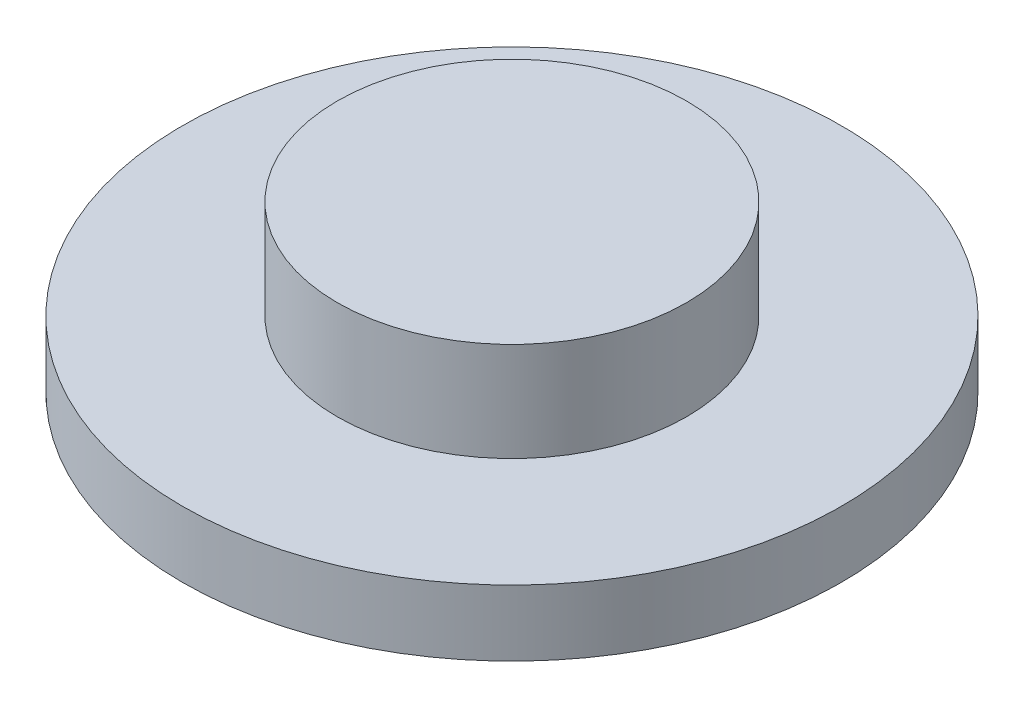
from build123d import *

# Parameters (mm, degrees)
SKETCH_1_R      = 15
EXTRUDE_1_DEPTH = 3
SKETCH_2_R      = 7.95
EXTRUDE_2_DEPTH = 4.5


with BuildPart() as part:
    # 草图1 → 凸台-拉伸1 (new body)
    with BuildSketch(Plane(origin=(0, 0, 0), x_dir=(1, 0, 0), z_dir=(0, 1, 0))):
        Circle(SKETCH_1_R)
    extrude(amount=EXTRUDE_1_DEPTH)

    # 草图2 → 凸台-拉伸2 (add)
    with BuildSketch(Plane(origin=(0, 3, 0), x_dir=(1, 0, 0), z_dir=(0, 1, 0))):
        Circle(SKETCH_2_R)
    extrude(amount=EXTRUDE_2_DEPTH)


solid = part.part
